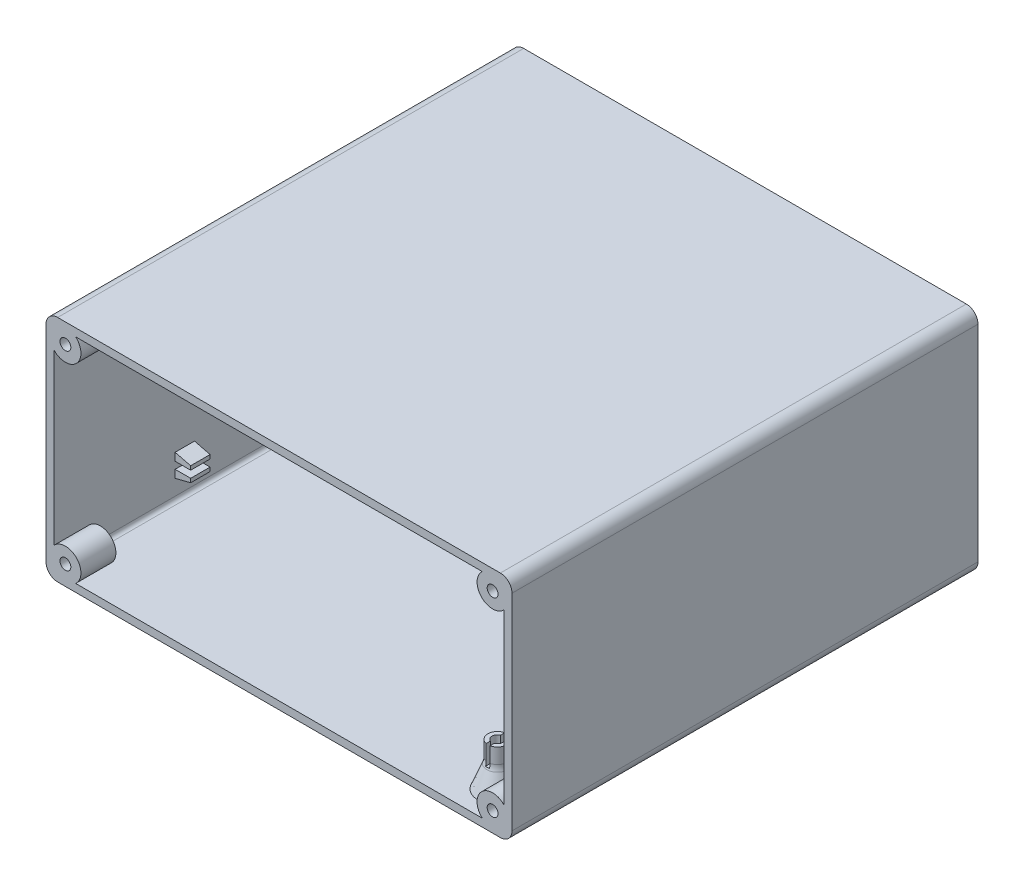
from build123d import *

# Parameters (mm, degrees)
EXTRUDE_1_DEPTH     = 120
SKETCH_5_R          = 4
SKETCH_5_R_2        = 1.4
EXTRUDE_3_DEPTH     = 9
SKETCH_6_R          = 4
SKETCH_6_R_2        = 1.4
EXTRUDE_4_DEPTH     = 9
CUT_EXTRUDE_1_DEPTH = 54
EXTRUDE_5_DEPTH     = 48
CUT_EXTRUDE_2_DEPTH = 5
EXTRUDE_6_DEPTH     = 2.5
SKETCH_12_R         = 1.4
CUT_EXTRUDE_3_DEPTH = 10
SKETCH_13_R         = 2.6
CUT_EXTRUDE_4_DEPTH = 2.5
SKETCH_15_R         = 1
CUT_EXTRUDE_5_DEPTH = 3


with BuildPart() as part:
    # 草图1 → 凸台-拉伸1 (new body)
    with BuildSketch(Plane.XY):
        with BuildLine():
            Line((-976.287380373, 27.058860709), (-862.287380373, 27.058860709))
            ThreePointArc((-862.287380373, 27.058860709), (-860.16606003, 26.180181052), (-859.287380373, 24.058860709))
            Line((-859.287380373, 24.058860709), (-859.287380373, -28.941139291))
            ThreePointArc((-859.287380373, -28.941139291), (-860.16606003, -31.062459635), (-862.287380373, -31.941139291))
            Line((-862.287380373, -31.941139291), (-976.287380373, -31.941139291))
            ThreePointArc((-976.287380373, -31.941139291), (-978.408700717, -31.062459635), (-979.287380373, -28.941139291))
            Line((-979.287380373, -28.941139291), (-979.287380373, 24.058860709))
            ThreePointArc((-979.287380373, 24.058860709), (-978.408700717, 26.180181052), (-976.287380373, 27.058860709))
        make_face()
        with BuildLine():
            Line((-976.287380373, 25.058860709), (-862.287380373, 25.058860709))
            ThreePointArc((-862.287380373, 25.058860709), (-861.580273592, 24.76596749), (-861.287380373, 24.058860709))
            Line((-861.287380373, 24.058860709), (-861.287380373, -28.941139291))
            ThreePointArc((-861.287380373, -28.941139291), (-861.580273592, -29.648246072), (-862.287380373, -29.941139291))
            Line((-862.287380373, -29.941139291), (-976.287380373, -29.941139291))
            ThreePointArc((-976.287380373, -29.941139291), (-976.994487154, -29.648246072), (-977.287380373, -28.941139291))
            Line((-977.287380373, -28.941139291), (-977.287380373, 24.058860709))
            ThreePointArc((-977.287380373, 24.058860709), (-976.994487154, 24.76596749), (-976.287380373, 25.058860709))
        make_face(mode=Mode.SUBTRACT)
    extrude(amount=EXTRUDE_1_DEPTH)

    # 草图5 → 凸台-拉伸3 (add)
    with BuildSketch(Plane.XY.offset(120)):
        with Locations((-974.291572676, 22.05371681)):
            Circle(SKETCH_5_R)
        with Locations((-974.291572676, 22.05371681)):
            Circle(SKETCH_5_R_2, mode=Mode.SUBTRACT)
        with Locations((-864.283188071, 22.05371681)):
            Circle(SKETCH_5_R)
        with Locations((-864.283188071, 22.05371681)):
            Circle(SKETCH_5_R_2, mode=Mode.SUBTRACT)
        with Locations((-864.283188071, -26.935995392)):
            Circle(SKETCH_5_R)
        with Locations((-864.283188071, -26.935995392)):
            Circle(SKETCH_5_R_2, mode=Mode.SUBTRACT)
        with Locations((-974.291572676, -26.935995392)):
            Circle(SKETCH_5_R)
        with Locations((-974.291572676, -26.935995392)):
            Circle(SKETCH_5_R_2, mode=Mode.SUBTRACT)
    extrude(amount=-EXTRUDE_3_DEPTH)

    # 草图6 → 凸台-拉伸4 (add)
    with BuildSketch(Plane(origin=(0, 0, 0), x_dir=(-1, 0, 0), z_dir=(0, 0, -1))):
        with Locations((864.283188071, 22.05371681)):
            Circle(SKETCH_6_R)
        with Locations((864.283188071, 22.05371681)):
            Circle(SKETCH_6_R_2, mode=Mode.SUBTRACT)
        with Locations((974.291572676, 22.05371681)):
            Circle(SKETCH_6_R)
        with Locations((974.291572676, 22.05371681)):
            Circle(SKETCH_6_R_2, mode=Mode.SUBTRACT)
        with Locations((974.291572676, -26.935995392)):
            Circle(SKETCH_6_R)
        with Locations((974.291572676, -26.935995392)):
            Circle(SKETCH_6_R_2, mode=Mode.SUBTRACT)
        with Locations((864.283188071, -26.935995392)):
            Circle(SKETCH_6_R)
        with Locations((864.283188071, -26.935995392)):
            Circle(SKETCH_6_R_2, mode=Mode.SUBTRACT)
    extrude(amount=-EXTRUDE_4_DEPTH)

    # 草图7 → 切除-拉伸1 (cut, symmetric)
    with BuildSketch(Plane.XY.offset(60)):
        Polygon((-972.703859436, 19.30371681), (-971.116146195, 22.05371681), (-972.703859436, 24.80371681), (-975.879285916, 24.80371681), (-977.466999156, 22.05371681), (-975.879285916, 19.30371681), align=None)
        Polygon((-862.69547483, 19.30371681), (-865.870901311, 19.30371681), (-867.458614551, 22.05371681), (-865.870901311, 24.80371681), (-862.69547483, 24.80371681), (-861.10776159, 22.05371681), align=None)
        Polygon((-865.870901311, -24.185995392), (-867.458614551, -26.935995392), (-865.870901311, -29.685995392), (-862.69547483, -29.685995392), (-861.10776159, -26.935995392), (-862.69547483, -24.185995392), align=None)
        Polygon((-975.879285916, -24.185995392), (-972.703859436, -24.185995392), (-971.116146195, -26.935995392), (-972.703859436, -29.685995392), (-975.879285916, -29.685995392), (-977.466999156, -26.935995392), align=None)
    extrude(amount=CUT_EXTRUDE_1_DEPTH, both=True, mode=Mode.SUBTRACT)

    # 草图8 → 凸台-拉伸5 (add, symmetric)
    with BuildSketch(Plane.XY.offset(60)):
        Polygon((-977.287380373, 21.742607951), (-977.287380373, 22.364825668), (-977.466999156, 22.05371681), align=None)
        Polygon((-861.10776159, 22.05371681), (-861.287380373, 21.742607951), (-861.287380373, 22.364825668), align=None)
        Polygon((-861.287380373, -26.624886534), (-861.287380373, -27.247104251), (-861.10776159, -26.935995392), align=None)
        Polygon((-977.466999156, -26.935995392), (-977.287380373, -26.624886534), (-977.287380373, -27.247104251), align=None)
    extrude(amount=EXTRUDE_5_DEPTH, both=True)

    # 草图9 → 旋转1 (revolve)
    with BuildSketch(Plane.ZY.offset(871.537380373)):
        with BuildLine():
            Line((61, -29.941139291), (61, -18.883806309))
            Line((61, -18.883806309), (58.55, -18.883806309))
            Line((58.55, -18.883806309), (58.55, -22.81079231))
            ThreePointArc((58.55, -22.81079231), (58.477478995, -23.569019682), (58.262545626, -24.299753348))
            Line((58.262545626, -24.299753348), (56, -29.941139291))
            Line((56, -29.941139291), (61, -29.941139291))
        make_face()
    revolve_1 = revolve(axis=Axis((-871.537380373, -29.941139291, 61), (0, 1, 0)))

    # 草图10 → 切除-拉伸2 (cut)
    with BuildSketch(Plane(origin=(0, -18.883806309, 0), x_dir=(1, 0, 0), z_dir=(0, 1, 0))):
        with BuildLine():
            Line((-872.037380373, -62.307669683), (-872.037380373, -64.216918104))
            Line((-872.037380373, -64.216918104), (-871.037380373, -64.216918104))
            Line((-871.037380373, -64.216918104), (-871.037380373, -62.307669683))
            ThreePointArc((-871.037380373, -62.307669683), (-870.137380373, -61), (-871.037380373, -59.692330317))
            Line((-871.037380373, -59.692330317), (-871.037380373, -57.783081896))
            Line((-871.037380373, -57.783081896), (-872.037380373, -57.783081896))
            Line((-872.037380373, -57.783081896), (-872.037380373, -59.692330317))
            ThreePointArc((-872.037380373, -59.692330317), (-872.937380373, -61), (-872.037380373, -62.307669683))
        make_face()
    cut_extrude_2 = extrude(amount=-CUT_EXTRUDE_2_DEPTH, mode=Mode.SUBTRACT)

    # 镜向3: 旋转1, 切除-拉伸2 across plane
    add(revolve_1.mirror(Plane.XY.offset(86.25)))
    add(cut_extrude_2.mirror(Plane.XY.offset(86.25)), mode=Mode.SUBTRACT)

    # 草图11 → 凸台-拉伸6 (add, symmetric)
    with BuildSketch(Plane.XY.offset(86.25)):
        Polygon((-977.287380373, -19.135995392), (-973.287380373, -20.135995392), (-973.287380373, -21.135995392), (-977.287380373, -21.135995392), align=None)
        Polygon((-977.287380373, -22.935995392), (-973.287380373, -22.935995392), (-973.287380373, -23.935995392), (-977.287380373, -24.935995392), align=None)
    extrude(amount=EXTRUDE_6_DEPTH, both=True)

    # 草图12 → 切除-拉伸3 (cut)
    with BuildSketch(Plane.XZ.offset(31.941139291)):
        with Locations((-871.537380373, 61)):
            Circle(SKETCH_12_R)
        with Locations((-871.537380373, 111.5)):
            Circle(SKETCH_12_R)
    extrude(amount=-CUT_EXTRUDE_3_DEPTH, mode=Mode.SUBTRACT)

    # 草图13 → 切除-拉伸4 (cut)
    with BuildSketch(Plane(origin=(0, -31.941139291, 0), x_dir=(-1, 0, 0), z_dir=(0, -1, 0))):
        with Locations((871.537380373, -61)):
            Circle(SKETCH_13_R)
        with Locations((871.537380373, -111.5)):
            Circle(SKETCH_13_R)
    extrude(amount=-CUT_EXTRUDE_4_DEPTH, mode=Mode.SUBTRACT)

    # 草图15 → 切除-拉伸5 (cut)
    with BuildSketch(Plane.ZY.offset(979.287380373)):
        with Locations((38.354297044, -2.330539987)):
            Circle(SKETCH_15_R)
        with Locations((38.354297044, 0.669460013)):
            Circle(SKETCH_15_R)
        with Locations((38.354297044, 3.669460013)):
            Circle(SKETCH_15_R)
        with Locations((38.354297044, 6.669460013)):
            Circle(SKETCH_15_R)
        with Locations((38.354297044, 9.669460013)):
            Circle(SKETCH_15_R)
        with Locations((38.354297044, 12.669460013)):
            Circle(SKETCH_15_R)
        with Locations((41.692111054, 12.293378695)):
            Circle(SKETCH_15_R)
        with Locations((44.862553131, 11.183993031)):
            Circle(SKETCH_15_R)
        with Locations((47.706644072, 9.39693225)):
            Circle(SKETCH_15_R)
        with Locations((50.081769281, 7.02180704)):
            Circle(SKETCH_15_R)
        with Locations((51.868830063, 4.177716099)):
            Circle(SKETCH_15_R)
        with Locations((52.978215727, 1.007274022)):
            Circle(SKETCH_15_R)
        with Locations((53.354297044, -2.330539987)):
            Circle(SKETCH_15_R)
        with Locations((52.978215727, -5.668353997)):
            Circle(SKETCH_15_R)
        with Locations((51.868830063, -8.838796074)):
            Circle(SKETCH_15_R)
        with Locations((50.081769281, -11.682887015)):
            Circle(SKETCH_15_R)
        with Locations((47.706644072, -14.058012225)):
            Circle(SKETCH_15_R)
        with Locations((44.862553131, -15.845073006)):
            Circle(SKETCH_15_R)
        with Locations((41.692111054, -16.95445867)):
            Circle(SKETCH_15_R)
        with Locations((38.354297044, -17.330539987)):
            Circle(SKETCH_15_R)
        with Locations((35.016483035, -16.95445867)):
            Circle(SKETCH_15_R)
        with Locations((31.846040958, -15.845073006)):
            Circle(SKETCH_15_R)
        with Locations((29.001950017, -14.058012225)):
            Circle(SKETCH_15_R)
        with Locations((26.626824807, -11.682887015)):
            Circle(SKETCH_15_R)
        with Locations((24.839764026, -8.838796074)):
            Circle(SKETCH_15_R)
        with Locations((23.730378362, -5.668353997)):
            Circle(SKETCH_15_R)
        with Locations((23.354297044, -2.330539987)):
            Circle(SKETCH_15_R)
        with Locations((23.730378362, 1.007274022)):
            Circle(SKETCH_15_R)
        with Locations((24.839764026, 4.177716099)):
            Circle(SKETCH_15_R)
        with Locations((26.626824807, 7.02180704)):
            Circle(SKETCH_15_R)
        with Locations((41.591858298, 9.224467461)):
            Circle(SKETCH_15_R)
        with Locations((44.589304445, 7.922492867)):
            Circle(SKETCH_15_R)
        with Locations((47.124328616, 5.860097731)):
            Circle(SKETCH_15_R)
        with Locations((49.008919665, 3.190240465)):
            Circle(SKETCH_15_R)
        with Locations((50.103306097, 0.110932169)):
            Circle(SKETCH_15_R)
        with Locations((50.326322275, -3.149448948)):
            Circle(SKETCH_15_R)
        with Locations((49.66142811, -6.349095334)):
            Circle(SKETCH_15_R)
        with Locations((48.157935761, -9.250703853)):
            Circle(SKETCH_15_R)
        with Locations((45.927352376, -11.639075476)):
            Circle(SKETCH_15_R)
        with Locations((43.135110123, -13.337075606)):
            Circle(SKETCH_15_R)
        with Locations((39.988296834, -14.21877134)):
            Circle(SKETCH_15_R)
        with Locations((36.720297255, -14.21877134)):
            Circle(SKETCH_15_R)
        with Locations((33.573483966, -13.337075606)):
            Circle(SKETCH_15_R)
        with Locations((30.781241713, -11.639075476)):
            Circle(SKETCH_15_R)
        with Locations((28.550658328, -9.250703853)):
            Circle(SKETCH_15_R)
        with Locations((27.047165979, -6.349095334)):
            Circle(SKETCH_15_R)
        with Locations((26.382271814, -3.149448948)):
            Circle(SKETCH_15_R)
        with Locations((26.605287992, 0.110932169)):
            Circle(SKETCH_15_R)
        with Locations((27.699674424, 3.190240465)):
            Circle(SKETCH_15_R)
        with Locations((41.60547204, 6.061710077)):
            Circle(SKETCH_15_R)
        with Locations((44.417557837, 4.320540268)):
            Circle(SKETCH_15_R)
        with Locations((46.410766667, 1.681105215)):
            Circle(SKETCH_15_R)
        with Locations((47.315904631, -1.500124752)):
            Circle(SKETCH_15_R)
        with Locations((47.010727833, -4.793506898)):
            Circle(SKETCH_15_R)
        with Locations((45.53645209, -7.754251715)):
            Circle(SKETCH_15_R)
        with Locations((43.09218651, -9.982494209)):
            Circle(SKETCH_15_R)
        with Locations((40.008042705, -11.177297885)):
            Circle(SKETCH_15_R)
        with Locations((36.700551384, -11.177297885)):
            Circle(SKETCH_15_R)
        with Locations((33.616407579, -9.982494209)):
            Circle(SKETCH_15_R)
        with Locations((31.172141999, -7.754251715)):
            Circle(SKETCH_15_R)
        with Locations((29.697866256, -4.793506898)):
            Circle(SKETCH_15_R)
        with Locations((29.392689458, -1.500124752)):
            Circle(SKETCH_15_R)
        with Locations((30.297827422, 1.681105215)):
            Circle(SKETCH_15_R)
        with Locations((41.354297044, 2.865612435)):
            Circle(SKETCH_15_R)
        with Locations((43.550449467, 0.669460013)):
            Circle(SKETCH_15_R)
        with Locations((44.354297044, -2.330539987)):
            Circle(SKETCH_15_R)
        with Locations((43.550449467, -5.330539987)):
            Circle(SKETCH_15_R)
        with Locations((41.354297044, -7.52669241)):
            Circle(SKETCH_15_R)
        with Locations((38.354297044, -8.330539987)):
            Circle(SKETCH_15_R)
        with Locations((35.354297044, -7.52669241)):
            Circle(SKETCH_15_R)
        with Locations((33.158144622, -5.330539987)):
            Circle(SKETCH_15_R)
        with Locations((32.354297044, -2.330539987)):
            Circle(SKETCH_15_R)
        with Locations((33.158144622, 0.669460013)):
            Circle(SKETCH_15_R)
        with Locations((35.354297044, 2.865612435)):
            Circle(SKETCH_15_R)
        with Locations((41.207466593, -1.403489004)):
            Circle(SKETCH_15_R)
        with Locations((40.117652801, -4.757590971)):
            Circle(SKETCH_15_R)
        with Locations((36.590941288, -4.757590971)):
            Circle(SKETCH_15_R)
        with Locations((35.501127496, -1.403489004)):
            Circle(SKETCH_15_R)
        with Locations((29.001950017, 9.39693225)):
            Circle(SKETCH_15_R)
        with Locations((31.846040958, 11.183993031)):
            Circle(SKETCH_15_R)
        with Locations((35.016483035, 12.293378695)):
            Circle(SKETCH_15_R)
        with Locations((29.584265473, 5.860097731)):
            Circle(SKETCH_15_R)
        with Locations((32.119289644, 7.922492867)):
            Circle(SKETCH_15_R)
        with Locations((35.116735791, 9.224467461)):
            Circle(SKETCH_15_R)
        with Locations((32.291036252, 4.320540268)):
            Circle(SKETCH_15_R)
        with Locations((35.103122049, 6.061710077)):
            Circle(SKETCH_15_R)
    extrude(amount=-CUT_EXTRUDE_5_DEPTH, mode=Mode.SUBTRACT)


solid = part.part
